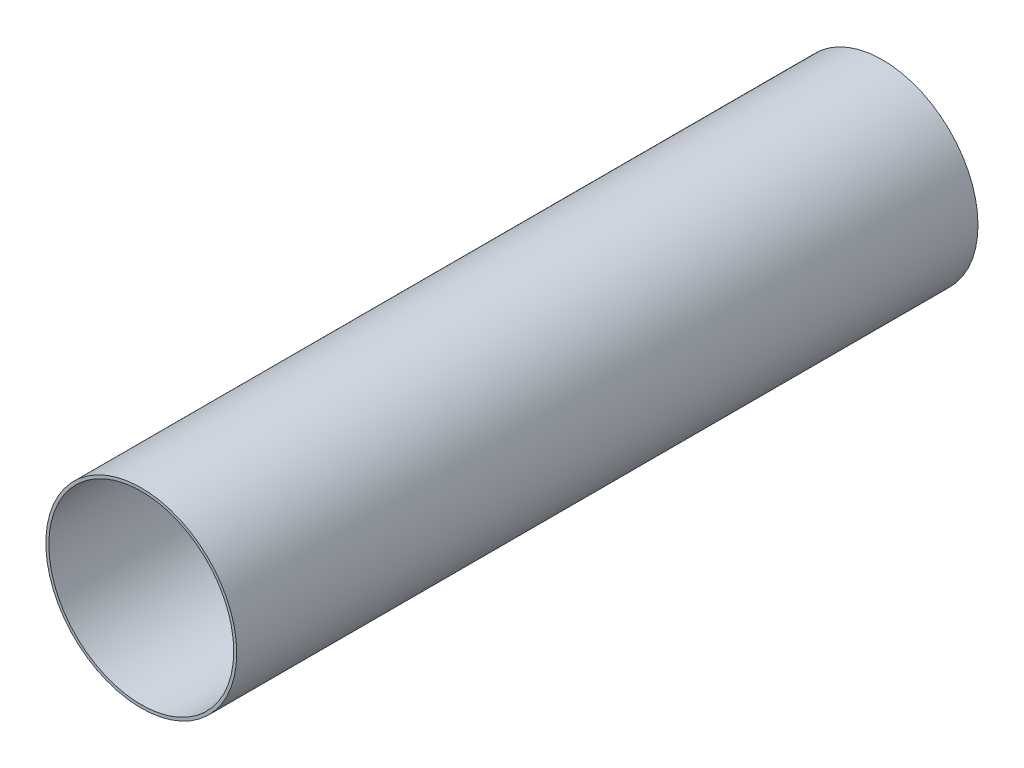
from build123d import *

# Parameters (mm, degrees)
SKETCH1_R           = 65.405
SKETCH1_R_2         = 63.373
BOSS_EXTRUDE1_DEPTH = 254


with BuildPart() as part:
    # Sketch1 → Boss-Extrude1 (new body, symmetric)
    with BuildSketch(Plane.XY):
        Circle(SKETCH1_R)
        Circle(SKETCH1_R_2, mode=Mode.SUBTRACT)
    extrude(amount=BOSS_EXTRUDE1_DEPTH, both=True)


solid = part.part
